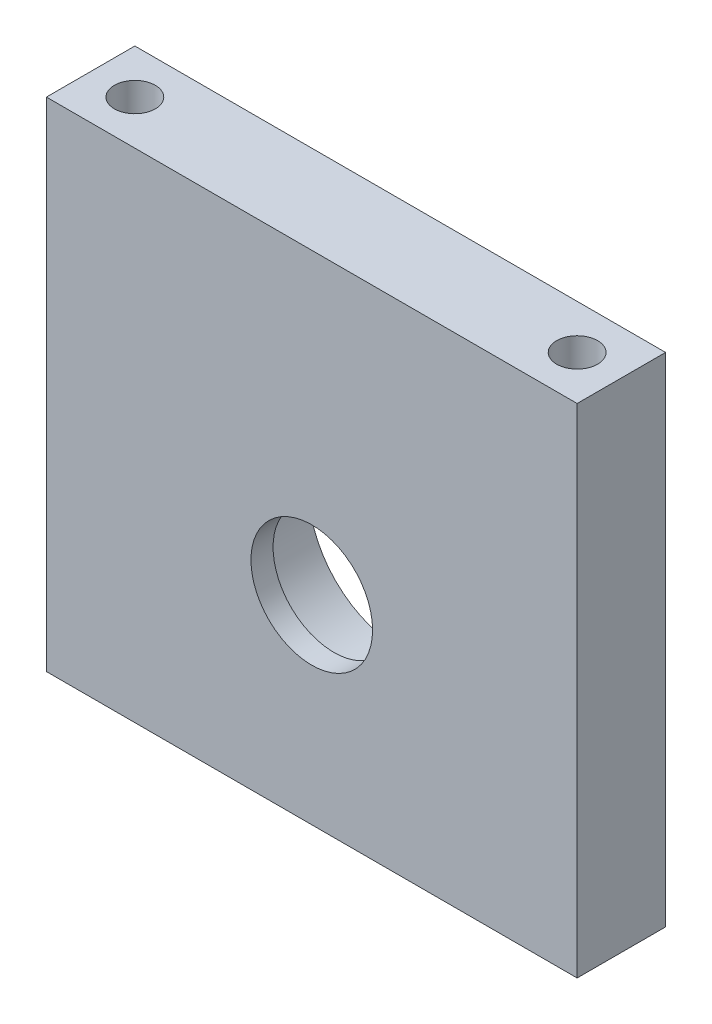
from build123d import *

# Parameters (mm, degrees)
ESQUISSE1_W                      = 48
ESQUISSE1_H                      = 45
BOSS_EXTRU_1_DEPTH               = 8
ESQUISSE5_R                      = 5.5
ENL_V_MAT_EXTRU_3_DEPTH          = 2
ESQUISSE4_R                      = 8.25
ENL_V_MAT_EXTRU_4_DEPTH          = 6
ESQUISSE2_R                      = 1.75
ENL_V_MAT_EXTRU_5_DEPTH          = 10
D_GAGEMENT_M3_51_D               = 3.7
D_GAGEMENT_M3_51_DEPTH           = 10
D_GAGEMENT_M3_51_TIP             = 1.111592145
D_GAGEMENT_M3_51_ON_FACE_2_D     = 3.7
D_GAGEMENT_M3_51_ON_FACE_2_DEPTH = 10
D_GAGEMENT_M3_51_ON_FACE_2_TIP   = 1.111592145


with BuildPart() as part:
    # Esquisse1 → Boss.-Extru.1 (new body)
    with BuildSketch(Plane.XY):
        Rectangle(ESQUISSE1_W, ESQUISSE1_H)
    extrude(amount=BOSS_EXTRU_1_DEPTH)

    # Esquisse5 → Enlèv. mat.-Extru.3 (cut)
    with BuildSketch(Plane.XY.offset(8)):
        with Locations((0, -4.5)):
            Circle(ESQUISSE5_R)
    extrude(amount=-ENL_V_MAT_EXTRU_3_DEPTH, mode=Mode.SUBTRACT)

    # Esquisse4 → Enlèv. mat.-Extru.4 (cut)
    with BuildSketch(Plane(origin=(0, 0, 0), x_dir=(-1, 0, 0), z_dir=(0, 0, -1))):
        with Locations((0, -4.5)):
            Circle(ESQUISSE4_R)
    extrude(amount=-ENL_V_MAT_EXTRU_4_DEPTH, mode=Mode.SUBTRACT)

    # Esquisse2 → Enlèv. mat.-Extru.5 (cut)
    with BuildSketch(Plane.XZ.offset(22.5)):
        with Locations((-20, 4)):
            Circle(ESQUISSE2_R)
        with Locations((20, 4)):
            Circle(ESQUISSE2_R)
    extrude(amount=-ENL_V_MAT_EXTRU_5_DEPTH, mode=Mode.SUBTRACT)

    # Dégagement M3.51
    with Locations(Plane(origin=(20, 22.5, 4), x_dir=(0, 0, 1), z_dir=(0, 1, 0))):
        with Locations((0, 0), (0, -40)):
            Hole(D_GAGEMENT_M3_51_D / 2, depth=D_GAGEMENT_M3_51_DEPTH)
            with Locations((0, 0, -(D_GAGEMENT_M3_51_DEPTH + D_GAGEMENT_M3_51_TIP / 2))):  # 118° drill point
                Cone(0, D_GAGEMENT_M3_51_D / 2, D_GAGEMENT_M3_51_TIP, mode=Mode.SUBTRACT)

    # Dégagement M3.51 on face 2
    with Locations(Plane(origin=(-58.361225935, 70.859654688, 0), x_dir=(0, 0, 1), z_dir=(0, 1, 0))):
        with Locations((0, 0)):
            Hole(D_GAGEMENT_M3_51_ON_FACE_2_D / 2, depth=D_GAGEMENT_M3_51_ON_FACE_2_DEPTH)
            with Locations((0, 0, -(D_GAGEMENT_M3_51_ON_FACE_2_DEPTH + D_GAGEMENT_M3_51_ON_FACE_2_TIP / 2))):  # 118° drill point
                Cone(0, D_GAGEMENT_M3_51_ON_FACE_2_D / 2, D_GAGEMENT_M3_51_ON_FACE_2_TIP, mode=Mode.SUBTRACT)


solid = part.part
